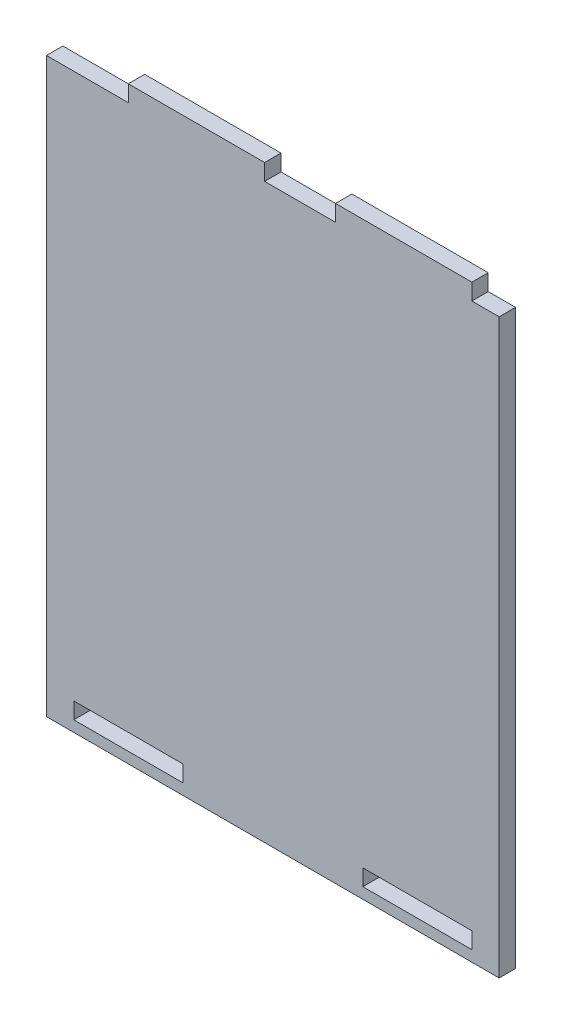
from build123d import *

# Parameters (mm, degrees)
RESSALTO_EXTRUS_O1_DEPTH = 3
ESBO_O2_W                = 20
ESBO_O2_H                = 3
CORTE_EXTRUS_O1_DEPTH    = 4


with BuildPart() as part:
    # Esboço1 → Ressalto-extrusão1 (new body)
    with BuildSketch(Plane.XY):
        Polygon((-26.514068493, 42.51552795), (-13.514068493, 42.51552795), (-13.514068493, 45.51552795), (11.485931507, 45.51552795), (11.485931507, 42.51552795), (16.485931507, 42.51552795), (16.485931507, -62.48447205), (-66.514068493, -62.48447205), (-66.514068493, 42.51552795), (-51.514068493, 42.51552795), (-51.514068493, 45.51552795), (-26.514068493, 45.51552795), align=None)
    extrude(amount=RESSALTO_EXTRUS_O1_DEPTH)

    # Esboço2 → Corte-extrusão1 (cut, through all)
    with BuildSketch(Plane(origin=(0, 0, 0), x_dir=(-1, 0, 0), z_dir=(0, 0, -1))):
        with Locations((51.514068493, -58.98447205)):
            Rectangle(ESBO_O2_W, ESBO_O2_H)
        with Locations((-1.485931507, -58.98447205)):
            Rectangle(ESBO_O2_W, ESBO_O2_H)
    extrude(amount=-CORTE_EXTRUS_O1_DEPTH, mode=Mode.SUBTRACT)


solid = part.part
